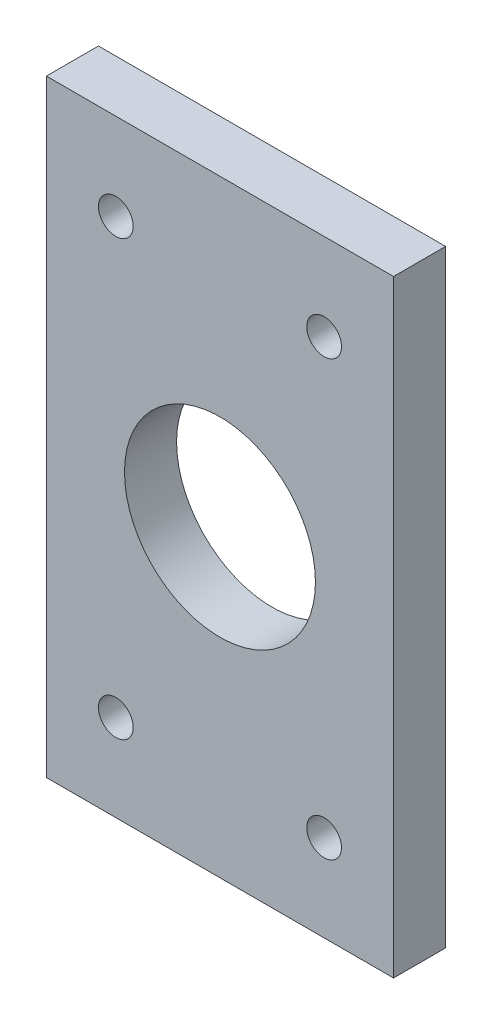
from build123d import *

# Parameters (mm, degrees)
SKETCH_1_W          = 40
SKETCH_1_H          = 70
SKETCH_1_R          = 11
EXTRUDE_1_DEPTH     = 6
SKETCH_2_R          = 2
CUT_EXTRUDE_1_DEPTH = 10


with BuildPart() as part:
    # 草图1 → 凸台-拉伸1 (new body)
    with BuildSketch(Plane.XY):
        with Locations((-20, 79.503169777)):
            Rectangle(SKETCH_1_W, SKETCH_1_H)
        with Locations((-20, 79.503169777)):
            Circle(SKETCH_1_R, mode=Mode.SUBTRACT)
    extrude(amount=EXTRUDE_1_DEPTH)

    # 草图2 → 切除-拉伸1 (cut)
    with BuildSketch(Plane.XY.offset(6)):
        with Locations((-32, 104.503169777)):
            Circle(SKETCH_2_R)
        with Locations((-8, 104.503169777)):
            Circle(SKETCH_2_R)
    cut_extrude_1 = extrude(amount=-CUT_EXTRUDE_1_DEPTH, mode=Mode.SUBTRACT)

    # 镜向1: 切除-拉伸1 across plane
    add(cut_extrude_1.mirror(Plane.ZX.offset(79.503169777)), mode=Mode.SUBTRACT)


solid = part.part
